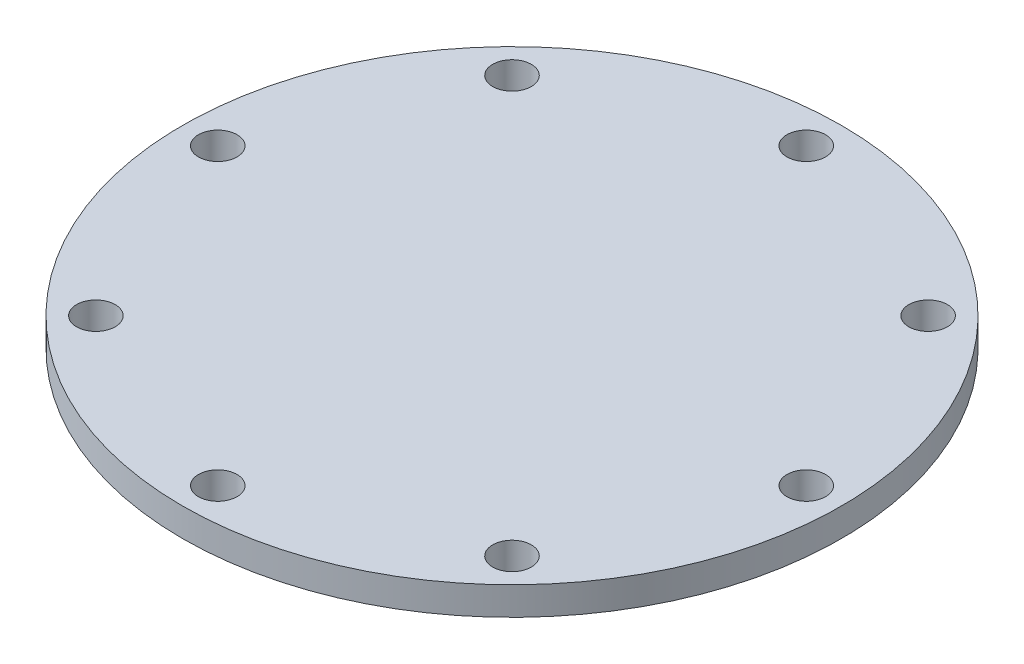
from build123d import *

# Parameters (mm, degrees)
ESQUISSE1_R        = 70
ESQUISSE1_R_2      = 4.1
BOSS_EXTRU_1_DEPTH = 6


with BuildPart() as part:
    # Esquisse1 → Boss.-Extru.1 (new body)
    with BuildSketch(Plane(origin=(0, 0, 0), x_dir=(1, 0, 0), z_dir=(0, 1, 0))):
        with Locations(Location((0, 0, 0), (0, 0, 270))):  # turned: the seam where the file's is
            Circle(ESQUISSE1_R)
        with Locations(Location((0, 62.5, 0), (0, 0, 270))):  # turned: the seam where the file's is
            Circle(ESQUISSE1_R_2, mode=Mode.SUBTRACT)
        with Locations(Location((44.194173824, 44.194173824, 0), (0, 0, 270))):  # turned: the seam where the file's is
            Circle(ESQUISSE1_R_2, mode=Mode.SUBTRACT)
        with Locations(Location((62.5, 0, 0), (0, 0, 270))):  # turned: the seam where the file's is
            Circle(ESQUISSE1_R_2, mode=Mode.SUBTRACT)
        with Locations(Location((44.194173824, -44.194173824, 0), (0, 0, 270))):  # turned: the seam where the file's is
            Circle(ESQUISSE1_R_2, mode=Mode.SUBTRACT)
        with Locations(Location((0, -62.5, 0), (0, 0, 270))):  # turned: the seam where the file's is
            Circle(ESQUISSE1_R_2, mode=Mode.SUBTRACT)
        with Locations(Location((-44.194173824, -44.194173824, 0), (0, 0, 270))):  # turned: the seam where the file's is
            Circle(ESQUISSE1_R_2, mode=Mode.SUBTRACT)
        with Locations(Location((-62.5, 0, 0), (0, 0, 270))):  # turned: the seam where the file's is
            Circle(ESQUISSE1_R_2, mode=Mode.SUBTRACT)
        with Locations(Location((-44.194173824, 44.194173824, 0), (0, 0, 270))):  # turned: the seam where the file's is
            Circle(ESQUISSE1_R_2, mode=Mode.SUBTRACT)
    extrude(amount=BOSS_EXTRU_1_DEPTH)


solid = part.part
